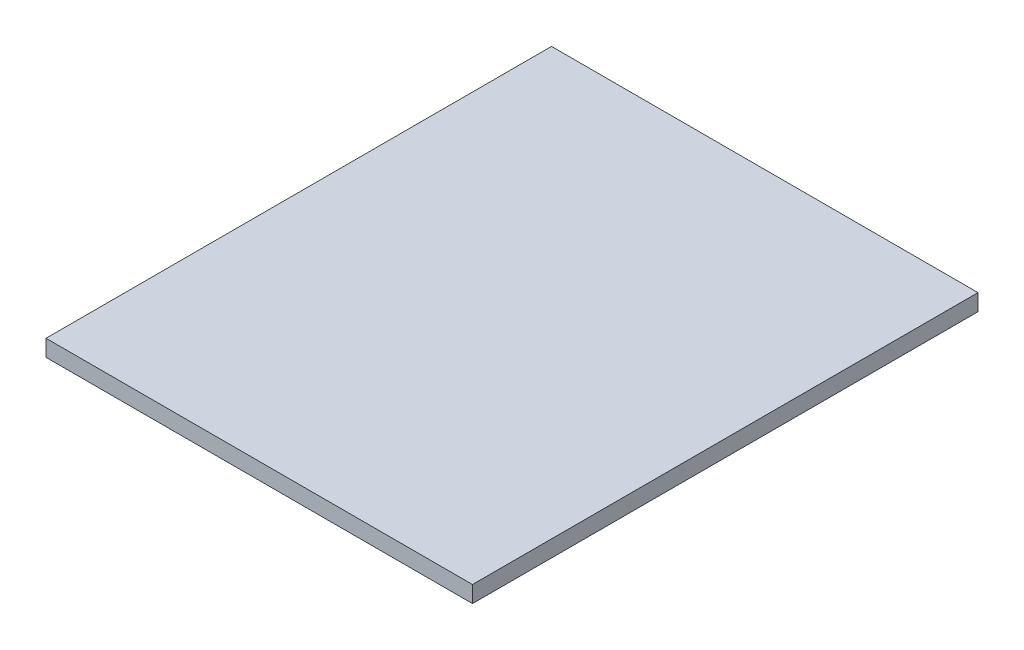
from build123d import *

# Parameters (mm, degrees)
SKETCH_1_W      = 464
SKETCH_1_H      = 550
EXTRUDE_1_DEPTH = 18


with BuildPart() as part:
    # Эскиз1 → Бобышка-Вытянуть1 (new body)
    with BuildSketch(Plane(origin=(0, 0, 0), x_dir=(1, 0, 0), z_dir=(0, 1, 0))):
        Rectangle(SKETCH_1_W, SKETCH_1_H)
    extrude(amount=EXTRUDE_1_DEPTH)


solid = part.part
